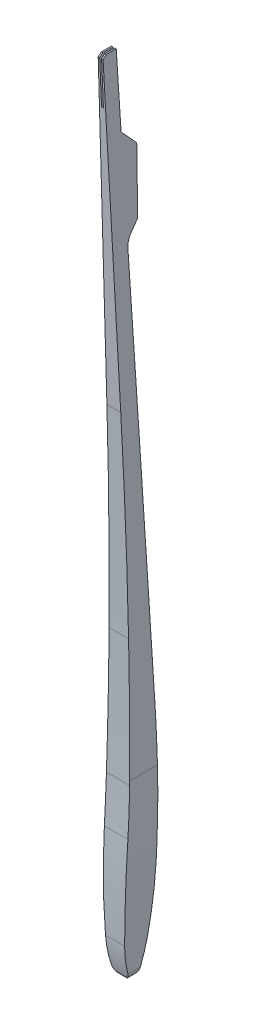
from build123d import *

# Parameters (mm, degrees)
BOSS_EXTRUDE1_DEPTH      = 31.75
BOSS_EXTRUDE1_DEPTH_BACK = 31.75
CUT_EXTRUDE2_DEPTH       = 1340.217520299
SKETCH3_W                = 3.175
SKETCH3_H                = 76.2
CUT_EXTRUDE3_DEPTH       = 1338.420695435


with BuildPart() as part:
    # Sketch1 → Boss-Extrude1 (new, two sides: drawn at the far end of the back side and taken through both)
    with BuildSketch(Plane(origin=(0, 0, 0), x_dir=(0, 0, -1), z_dir=(1, 0, 0)).offset(-BOSS_EXTRUDE1_DEPTH_BACK)):
        with BuildLine():
            Line((1.021340573, 1065.671760022), (10.69404187, 1079.103015809))
            ThreePointArc((10.69404187, 1079.103015809), (11.573445276, 1080.842426323), (11.876332412, 1082.767824636))
            Line((11.876332412, 1082.767824636), (11.876332412, 1187.719530026))
            Line((11.876332412, 1187.719530026), (-13.536061703, 1215.286446683))
            Line((-13.536061703, 1215.286446683), (-19.823769094, 1336.738131825))
            Line((-19.823769094, 1336.738131825), (-36.668668575, 1336.738131825))
            Line((-36.668668575, 1336.738131825), (-41.611308298, 1332.181789519))
            Line((-41.611308298, 1332.181789519), (-19.823769313, 820.101609747))
            ThreePointArc((-19.823769313, 820.101609747), (-14.269049163, 657.404177816), (-11.609546724, 494.633675821))
            ThreePointArc((-11.609546724, 494.633675821), (-11.552697494, 390.848511752), (-12.926889154, 287.072430162))
            ThreePointArc((-12.926889154, 287.072430162), (-14.08497073, 249.282151425), (-16.036320575, 211.524522345))
            ThreePointArc((-16.036320575, 211.524522345), (-18.862629391, 134.694563635), (-17.789412377, 57.820128469))
            ThreePointArc((-17.789412377, 57.820128469), (-14.713555739, 31.224003963), (-7.655684583, 5.397637832))
            ThreePointArc((-7.655684583, 5.397637832), (0, 0), (7.655684583, 5.397637832))
            ThreePointArc((7.655684583, 5.397637832), (14.877278089, 28.754462777), (20.079353087, 52.642348827))
            ThreePointArc((20.079353087, 52.642348827), (27.352586181, 104.395526294), (31.292623673, 156.508551558))
            ThreePointArc((31.292623673, 156.508551558), (31.58109291, 163.474292498), (31.841795924, 170.441127883))
            ThreePointArc((31.841795924, 170.441127883), (33.322524829, 278.033900996), (30.144822487, 385.589931009))
            ThreePointArc((30.144822487, 385.589931009), (12.959303763, 715.76096893), (-4.76677265, 1045.903426895))
            ThreePointArc((-4.76677265, 1045.903426895), (-3.565814336, 1056.283327954), (1.021340573, 1065.671760022))
        make_face()
    extrude(amount=BOSS_EXTRUDE1_DEPTH + BOSS_EXTRUDE1_DEPTH_BACK)

    # Sketch2 → Cut-Extrude2 (cut, through all)
    with BuildSketch(Plane.XY.offset(-33.399831543)):
        with BuildLine():
            Line((-31.75, 0), (0, 0))
            ThreePointArc((0, 0), (-9.440831446, 3.765721828), (-13.698146022, 12.995306427))
            ThreePointArc((-13.698146022, 12.995306427), (-18.724333894, 153.044911462), (-19.05, 293.18430056))
            Line((-19.05, 293.18430056), (-3.96875, 1336.738131825))
            Line((-3.96875, 1336.738131825), (-31.75, 1336.738131825))
            Line((-31.75, 1336.738131825), (-31.75, 0))
        make_face()
        with BuildLine():
            Line((3.96875, 1336.738131825), (19.05, 293.18430056))
            ThreePointArc((19.05, 293.18430056), (18.724333894, 153.044911462), (13.698146022, 12.995306427))
            ThreePointArc((13.698146022, 12.995306427), (9.440831446, 3.765721828), (0, 0))
            Line((0, 0), (31.75, 0))
            Line((31.75, 0), (31.75, 1336.738131825))
            Line((31.75, 1336.738131825), (3.96875, 1336.738131825))
        make_face()
    extrude(amount=CUT_EXTRUDE2_DEPTH, mode=Mode.SUBTRACT)

    # Sketch3 → Cut-Extrude3 (cut, through all)
    with BuildSketch(Plane(origin=(0, 2.549675539, -49.248855197), x_dir=(-1, 0, 0), z_dir=(0, 0.051702023951454394, -0.9986625559814103))):
        with Locations((0, 1298.746163787)):
            Rectangle(SKETCH3_W, SKETCH3_H)
    extrude(amount=-CUT_EXTRUDE3_DEPTH, mode=Mode.SUBTRACT)


solid = part.part
